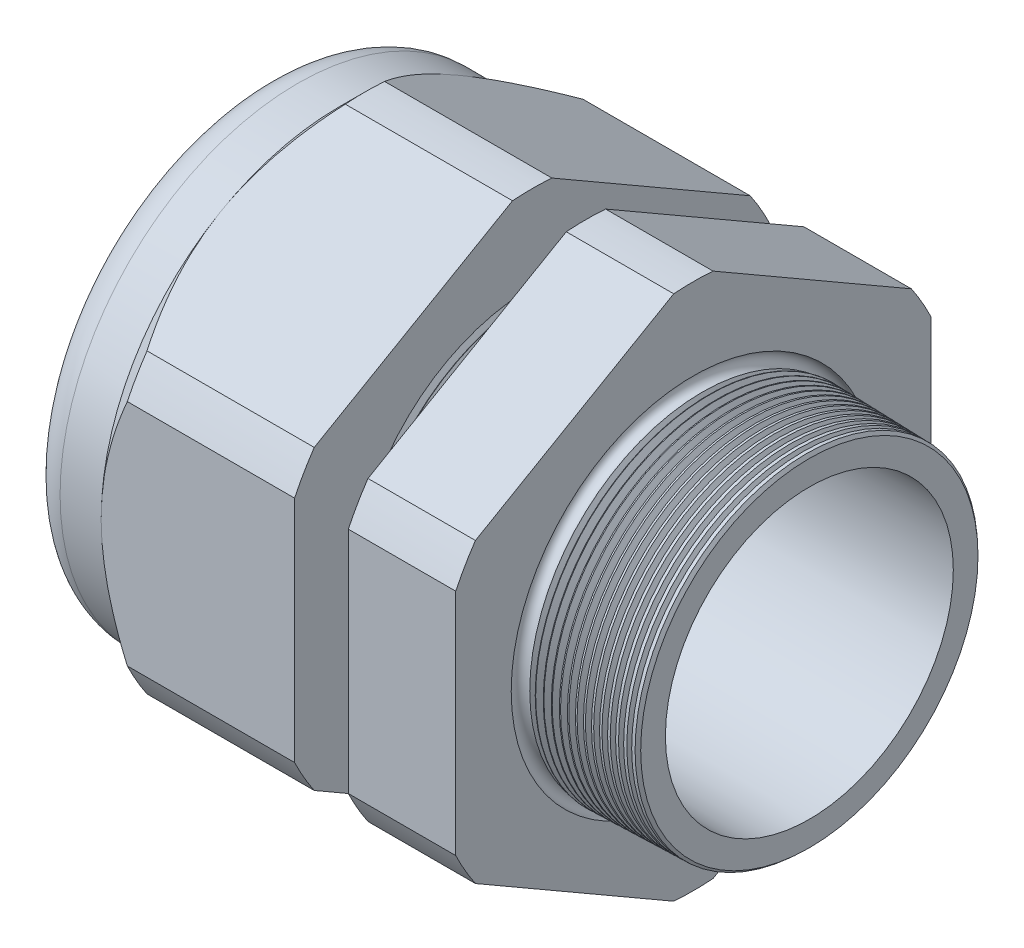
from build123d import *

# Parameters (mm, degrees)
SKETCH12_OUTSIDE_W = 140.582
SKETCH12_OUTSIDE_H = 140.582
CUT_EXTRUDE2_DEPTH = 53.5600168
FILLET4_R          = 3.81
SKETCH19_OUTSIDE_W = 83.088
SKETCH19_OUTSIDE_H = 88.928
SKETCH19_OUTSIDE_R = 26.543
CUT_EXTRUDE3_DEPTH = 3.99796
CUT_EXTRUDE3_DRAFT = -45
CHAMFER1_SIZE      = 0.260919487
CHAMFER1_SIZE2     = 0.254
SKETCH21_R         = 16.002
PLUG_DEPTH         = 12.7
SKETCH22_R         = 15.748
CUT_EXTRUDE4_DEPTH = 0.508
SKETCH27_R         = 4.445
PLUGHOLES_DEPTH    = 61.452
CIRPATTERN1_COUNT  = 7
LPATTERN1_COUNT    = 8
LPATTERN1_PITCH    = 0.762
LPATTERN2_COUNT    = 15
LPATTERN2_PITCH    = 0.889
SKETCH32_R         = 0.889


with BuildPart() as part:
    # Sketch10 → Revolve2 (revolve)
    with BuildSketch(Plane.XY, mode=Mode.PRIVATE) as revolve2_sk:
        Polygon((-55.88, 16.002), (-25.87759112, 16.002), (5.08, 16.080346947), (5.08, 19.128346947), (-7.874, 19.467559375), (-7.874, 53.086), (-19.873976, 53.086), (-19.873976, 19.781789805), (-25.87759112, 19.939), (-25.87759112, 53.086), (-47.4800168, 53.086), (-47.4800168, 26.543), (-55.88, 26.543), align=None)
    revolve(revolve2_sk.sketch.rotate(Axis((0, 0, 0), (-1, 0, 0)), 90), axis=Axis((0, 0, 0), (-1, 0, 0)))  # turned: the seam where the file's is

    # Sketch12 outside → Cut-Extrude2 (cut, through all)
    with BuildSketch(Plane.ZY.offset(47.4800168)):
        Rectangle(SKETCH12_OUTSIDE_W, SKETCH12_OUTSIDE_H)
        with BuildLine():
            Line((-2.19715092, 29.380690715), (-24.34584908, 16.59313387))
            ThreePointArc((-24.34584908, 16.59313387), (-25.515472645, 14.731365), (-26.543, 12.787556845))
            Line((-26.543, 12.787556845), (-26.543, -12.787556845))
            ThreePointArc((-26.543, -12.787556845), (-25.515472645, -14.731365), (-24.34584908, -16.59313387))
            Line((-24.34584908, -16.59313387), (-2.19715092, -29.380690715))
            ThreePointArc((-2.19715092, -29.380690715), (0, -29.46273), (2.19715092, -29.380690715))
            Line((2.19715092, -29.380690715), (24.34584908, -16.59313387))
            ThreePointArc((24.34584908, -16.59313387), (25.515472645, -14.731365), (26.543, -12.787556845))
            Line((26.543, -12.787556845), (26.543, 12.787556845))
            ThreePointArc((26.543, 12.787556845), (25.515472645, 14.731365), (24.34584908, 16.59313387))
            Line((24.34584908, 16.59313387), (2.19715092, 29.380690715))
            ThreePointArc((2.19715092, 29.380690715), (0, 29.46273), (-2.19715092, 29.380690715))
        make_face(mode=Mode.SUBTRACT)
    extrude(amount=-CUT_EXTRUDE2_DEPTH, mode=Mode.SUBTRACT)

    # Fillet4
    fillet4_edges = [part.edges().sort_by_distance(p)[0] for p in [
        (-55.88, 0, 26.543),
    ]]
    fillet(fillet4_edges, radius=FILLET4_R)


with BuildPart() as cut_extrude3_tool:
    # Sketch19 outside → Cut-Extrude3 (with draft: the straight prism first)
    with BuildSketch(Plane.ZY.offset(47.4800168)):
        Rectangle(SKETCH19_OUTSIDE_W, SKETCH19_OUTSIDE_H)
        Circle(SKETCH19_OUTSIDE_R, mode=Mode.SUBTRACT)
    extrude(amount=-CUT_EXTRUDE3_DEPTH)
    # Cut-Extrude3: the draft: its side faces are tilted about the plane it starts from
    cut_extrude3_sides = [cut_extrude3_tool.faces().sort_by_distance(p)[0] for p in [
        (-45.4810368, -44.464, 0),
        (-45.4810368, 0, 41.544),
        (-45.4810368, 44.464, 0),
        (-45.4810368, 0, -41.544),
        (-45.4810368, 0, -26.543),
    ]]
    draft(cut_extrude3_sides, Plane.ZY.offset(47.4800168), CUT_EXTRUDE3_DRAFT)


with BuildPart() as part_1:
    add(part.part)

    # Cut-Extrude3: cut by cut_extrude3_tool
    add(cut_extrude3_tool.part, mode=Mode.SUBTRACT)

    # Chamfer1
    chamfer1_edges = [part_1.edges().sort_by_distance(p)[0] for p in [
        (5.08, 0, 19.128346947),
    ]]
    chamfer1_side = [part_1.faces().sort_by_distance(p)[0] for p in [
        (5.08, 0, 16.621378301),
    ]]
    chamfer(chamfer1_edges, length=CHAMFER1_SIZE, length2=CHAMFER1_SIZE2, reference=chamfer1_side[0])

    # Sketch29 → Cut-Revolve1 (revolve, cut)
    with BuildSketch(Plane.XY, mode=Mode.PRIVATE) as cut_revolve1_sk:
        Polygon((-25.87759112, 19.939), (-25.144607539, 19.919806149), (-25.527721692, 19.294620673), align=None)
    cut_revolve1 = revolve(cut_revolve1_sk.sketch.rotate(Axis((0, 0, 0), (-1, 0, 0)), 90), axis=Axis((0, 0, 0), (-1, 0, 0)), mode=Mode.SUBTRACT)  # turned: the seam where the file's is

    # LPattern1: Cut-Revolve1 ×8
    with Locations(*[(i * LPATTERN1_PITCH, 0, 0) for i in range(1, LPATTERN1_COUNT)]):
        add(cut_revolve1, mode=Mode.SUBTRACT)

    # Sketch30 → Cut-Revolve2 (revolve, cut)
    with BuildSketch(Plane.XY, mode=Mode.PRIVATE) as cut_revolve2_sk:
        Polygon((-7.874, 19.467559375), (-6.994419703, 19.444526754), (-7.454156686, 18.694304183), align=None)
    cut_revolve2 = revolve(cut_revolve2_sk.sketch.rotate(Axis((0, 0, 0), (-1, 0, 0)), 270), axis=Axis((0, 0, 0), (-1, 0, 0)), mode=Mode.SUBTRACT)  # turned: the seam where the file's is

    # LPattern2: Cut-Revolve2 ×15
    with Locations(*[(i * LPATTERN2_PITCH, 0, 0) for i in range(1, LPATTERN2_COUNT)]):
        add(cut_revolve2, mode=Mode.SUBTRACT)

    # Sketch32 → Cut-Revolve3 (revolve, cut)
    with BuildSketch(Plane.XY, mode=Mode.PRIVATE) as cut_revolve3_sk:
        with Locations((-7.747, 19.467559375)):
            Circle(SKETCH32_R)
    revolve(cut_revolve3_sk.sketch.rotate(Axis((0, 0, 0), (-1, 0, 0)), 270), axis=Axis((0, 0, 0), (-1, 0, 0)), mode=Mode.SUBTRACT)  # turned: the seam where the file's is


with BuildPart() as body_2:
    # Sketch21 → plug (new body)
    with BuildSketch(Plane.ZY.offset(55.88)):
        Circle(SKETCH21_R)
    extrude(amount=-PLUG_DEPTH)

    # Sketch22 → Cut-Extrude4 (cut)
    with BuildSketch(Plane.ZY.offset(55.88)):
        Circle(SKETCH22_R)
    extrude(amount=-CUT_EXTRUDE4_DEPTH, mode=Mode.SUBTRACT)

    # Sketch27 → plugholes (cut, through all)
    with BuildSketch(Plane.ZY.offset(55.372)):
        with Locations((-11.28522, 0)):
            Circle(SKETCH27_R)
    plugholes = extrude(amount=-PLUGHOLES_DEPTH, mode=Mode.SUBTRACT)

    # CirPattern1: plugholes ×7 about axis
    cirpattern1_axis = Axis((0, 0, 0), (1, 0, 0))
    for i in range(1, CIRPATTERN1_COUNT):
        add(plugholes.rotate(cirpattern1_axis, i * 360 / CIRPATTERN1_COUNT), mode=Mode.SUBTRACT)


solid = Compound([part_1.part, body_2.part])
